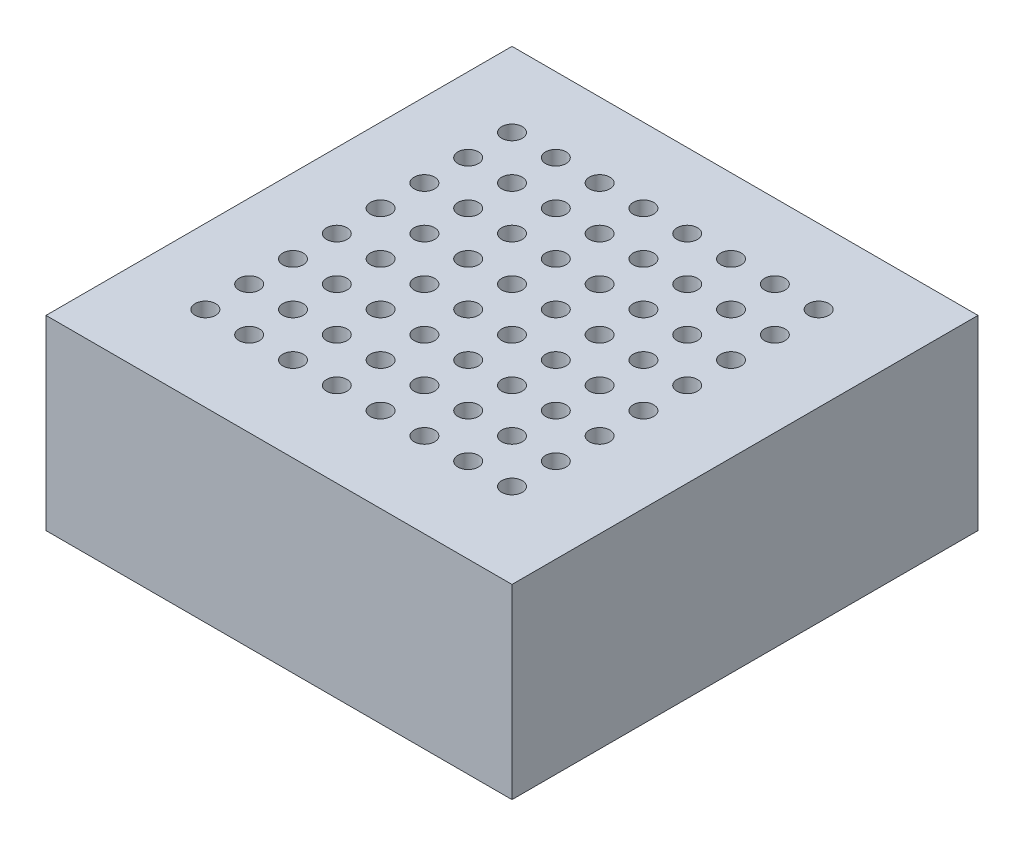
from build123d import *

# Parameters (mm, degrees)
SKETCH1_W           = 25
SKETCH1_H           = 25
SKETCH1_R           = 0.55
BOSS_EXTRUDE1_DEPTH = 10


with BuildPart() as part:
    # Sketch1 → Boss-Extrude1 (new body)
    with BuildSketch(Plane(origin=(0, 0, 0), x_dir=(1, 0, 0), z_dir=(0, 1, 0))):
        Rectangle(SKETCH1_W, SKETCH1_H)
        with Locations((-8.5, 8.5)):
            Circle(SKETCH1_R, mode=Mode.SUBTRACT)
        with Locations((-6.15, 8.5)):
            Circle(SKETCH1_R, mode=Mode.SUBTRACT)
        with Locations((-3.8, 8.5)):
            Circle(SKETCH1_R, mode=Mode.SUBTRACT)
        with Locations((-1.45, 8.5)):
            Circle(SKETCH1_R, mode=Mode.SUBTRACT)
        with Locations((0.9, 8.5)):
            Circle(SKETCH1_R, mode=Mode.SUBTRACT)
        with Locations((3.25, 8.5)):
            Circle(SKETCH1_R, mode=Mode.SUBTRACT)
        with Locations((5.6, 8.5)):
            Circle(SKETCH1_R, mode=Mode.SUBTRACT)
        with Locations((7.95, 8.5)):
            Circle(SKETCH1_R, mode=Mode.SUBTRACT)
        with Locations((-6.15, 6.15)):
            Circle(SKETCH1_R, mode=Mode.SUBTRACT)
        with Locations((-3.8, 6.15)):
            Circle(SKETCH1_R, mode=Mode.SUBTRACT)
        with Locations((-1.45, 6.15)):
            Circle(SKETCH1_R, mode=Mode.SUBTRACT)
        with Locations((0.9, 6.15)):
            Circle(SKETCH1_R, mode=Mode.SUBTRACT)
        with Locations((3.25, 6.15)):
            Circle(SKETCH1_R, mode=Mode.SUBTRACT)
        with Locations((5.6, 6.15)):
            Circle(SKETCH1_R, mode=Mode.SUBTRACT)
        with Locations((7.95, 6.15)):
            Circle(SKETCH1_R, mode=Mode.SUBTRACT)
        with Locations((-6.15, 3.8)):
            Circle(SKETCH1_R, mode=Mode.SUBTRACT)
        with Locations((-3.8, 3.8)):
            Circle(SKETCH1_R, mode=Mode.SUBTRACT)
        with Locations((-1.45, 3.8)):
            Circle(SKETCH1_R, mode=Mode.SUBTRACT)
        with Locations((0.9, 3.8)):
            Circle(SKETCH1_R, mode=Mode.SUBTRACT)
        with Locations((3.25, 3.8)):
            Circle(SKETCH1_R, mode=Mode.SUBTRACT)
        with Locations((5.6, 3.8)):
            Circle(SKETCH1_R, mode=Mode.SUBTRACT)
        with Locations((7.95, 3.8)):
            Circle(SKETCH1_R, mode=Mode.SUBTRACT)
        with Locations((-6.15, 1.45)):
            Circle(SKETCH1_R, mode=Mode.SUBTRACT)
        with Locations((-3.8, 1.45)):
            Circle(SKETCH1_R, mode=Mode.SUBTRACT)
        with Locations((-1.45, 1.45)):
            Circle(SKETCH1_R, mode=Mode.SUBTRACT)
        with Locations((0.9, 1.45)):
            Circle(SKETCH1_R, mode=Mode.SUBTRACT)
        with Locations((3.25, 1.45)):
            Circle(SKETCH1_R, mode=Mode.SUBTRACT)
        with Locations((5.6, 1.45)):
            Circle(SKETCH1_R, mode=Mode.SUBTRACT)
        with Locations((7.95, 1.45)):
            Circle(SKETCH1_R, mode=Mode.SUBTRACT)
        with Locations((-6.15, -0.9)):
            Circle(SKETCH1_R, mode=Mode.SUBTRACT)
        with Locations((-3.8, -0.9)):
            Circle(SKETCH1_R, mode=Mode.SUBTRACT)
        with Locations((-1.45, -0.9)):
            Circle(SKETCH1_R, mode=Mode.SUBTRACT)
        with Locations((0.9, -0.9)):
            Circle(SKETCH1_R, mode=Mode.SUBTRACT)
        with Locations((3.25, -0.9)):
            Circle(SKETCH1_R, mode=Mode.SUBTRACT)
        with Locations((5.6, -0.9)):
            Circle(SKETCH1_R, mode=Mode.SUBTRACT)
        with Locations((7.95, -0.9)):
            Circle(SKETCH1_R, mode=Mode.SUBTRACT)
        with Locations((-6.15, -3.25)):
            Circle(SKETCH1_R, mode=Mode.SUBTRACT)
        with Locations((-3.8, -3.25)):
            Circle(SKETCH1_R, mode=Mode.SUBTRACT)
        with Locations((-1.45, -3.25)):
            Circle(SKETCH1_R, mode=Mode.SUBTRACT)
        with Locations((0.9, -3.25)):
            Circle(SKETCH1_R, mode=Mode.SUBTRACT)
        with Locations((3.25, -3.25)):
            Circle(SKETCH1_R, mode=Mode.SUBTRACT)
        with Locations((5.6, -3.25)):
            Circle(SKETCH1_R, mode=Mode.SUBTRACT)
        with Locations((7.95, -3.25)):
            Circle(SKETCH1_R, mode=Mode.SUBTRACT)
        with Locations((-6.15, -5.6)):
            Circle(SKETCH1_R, mode=Mode.SUBTRACT)
        with Locations((-3.8, -5.6)):
            Circle(SKETCH1_R, mode=Mode.SUBTRACT)
        with Locations((-1.45, -5.6)):
            Circle(SKETCH1_R, mode=Mode.SUBTRACT)
        with Locations((0.9, -5.6)):
            Circle(SKETCH1_R, mode=Mode.SUBTRACT)
        with Locations((3.25, -5.6)):
            Circle(SKETCH1_R, mode=Mode.SUBTRACT)
        with Locations((5.6, -5.6)):
            Circle(SKETCH1_R, mode=Mode.SUBTRACT)
        with Locations((7.95, -5.6)):
            Circle(SKETCH1_R, mode=Mode.SUBTRACT)
        with Locations((-6.15, -7.95)):
            Circle(SKETCH1_R, mode=Mode.SUBTRACT)
        with Locations((-3.8, -7.95)):
            Circle(SKETCH1_R, mode=Mode.SUBTRACT)
        with Locations((-1.45, -7.95)):
            Circle(SKETCH1_R, mode=Mode.SUBTRACT)
        with Locations((0.9, -7.95)):
            Circle(SKETCH1_R, mode=Mode.SUBTRACT)
        with Locations((3.25, -7.95)):
            Circle(SKETCH1_R, mode=Mode.SUBTRACT)
        with Locations((5.6, -7.95)):
            Circle(SKETCH1_R, mode=Mode.SUBTRACT)
        with Locations((7.95, -7.95)):
            Circle(SKETCH1_R, mode=Mode.SUBTRACT)
        with Locations((-8.5, 6.15)):
            Circle(SKETCH1_R, mode=Mode.SUBTRACT)
        with Locations((-8.5, 3.8)):
            Circle(SKETCH1_R, mode=Mode.SUBTRACT)
        with Locations((-8.5, 1.45)):
            Circle(SKETCH1_R, mode=Mode.SUBTRACT)
        with Locations((-8.5, -0.9)):
            Circle(SKETCH1_R, mode=Mode.SUBTRACT)
        with Locations((-8.5, -3.25)):
            Circle(SKETCH1_R, mode=Mode.SUBTRACT)
        with Locations((-8.5, -5.6)):
            Circle(SKETCH1_R, mode=Mode.SUBTRACT)
        with Locations((-8.5, -7.95)):
            Circle(SKETCH1_R, mode=Mode.SUBTRACT)
    extrude(amount=BOSS_EXTRUDE1_DEPTH)


solid = part.part
